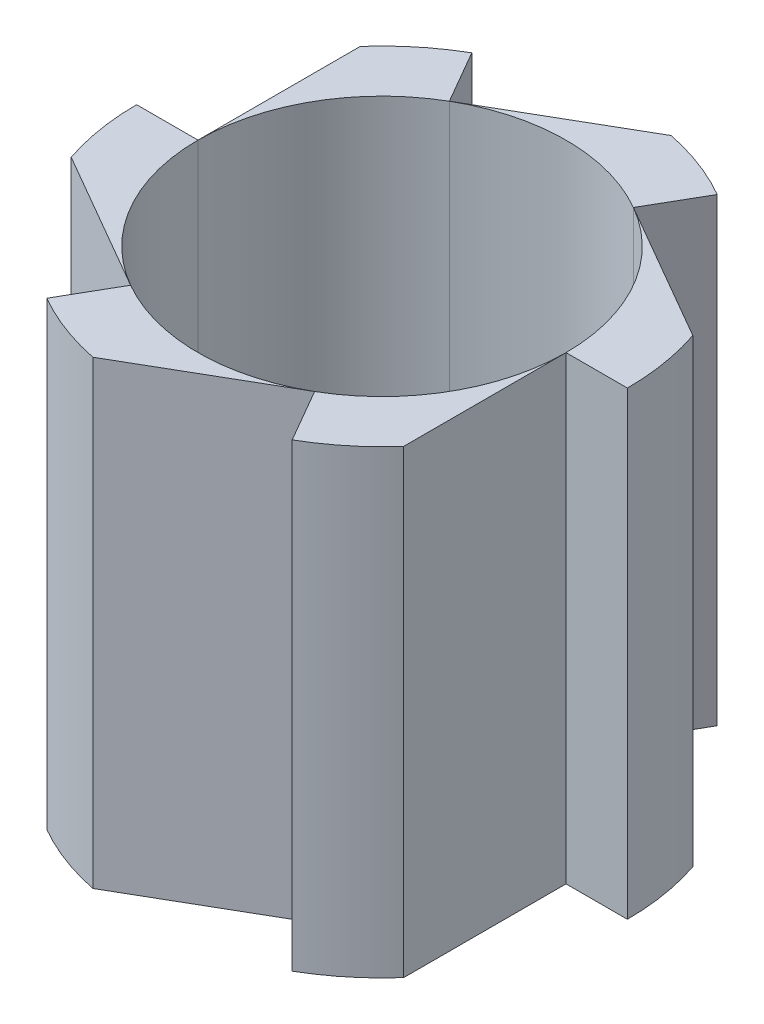
from build123d import *

# Parameters (mm, degrees)
BOSS_EXTRUDE1_DEPTH   = 45
BOSS_EXTRUDE1_2_DEPTH = 45
BOSS_EXTRUDE1_3_DEPTH = 45
BOSS_EXTRUDE1_4_DEPTH = 45
BOSS_EXTRUDE1_5_DEPTH = 45
BOSS_EXTRUDE1_6_DEPTH = 45


with BuildPart() as part:
    # Sketch1 → Boss-Extrude1 (new body)
    with BuildSketch(Plane(origin=(0, 0, 0), x_dir=(1, 0, 0), z_dir=(0, 1, 0))):
        with BuildLine():
            Line((-4.747727085, -23.525711201), (9, -15.588457268))
            ThreePointArc((9, -15.588457268), (0, -18), (-9, -15.588457268))
            Line((-9, -15.588457268), (-12, -20.784609691))
            ThreePointArc((-12, -20.784609691), (-8.485281374, -22.449944321), (-4.747727085, -23.525711201))
        make_face()
    extrude(amount=BOSS_EXTRUDE1_DEPTH)


with BuildPart() as body_2:
    # Sketch1 → Boss-Extrude1 2 (new body)
    with BuildSketch(Plane(origin=(0, 0, 0), x_dir=(1, 0, 0), z_dir=(0, 1, 0))):
        with BuildLine():
            Line((18, -15.874507866), (18, 0))
            ThreePointArc((18, 0), (15.588457268, -9), (9, -15.588457268))
            Line((9, -15.588457268), (12, -20.784609691))
            ThreePointArc((12, -20.784609691), (15.199581408, -18.573441389), (18, -15.874507866))
        make_face()
    extrude(amount=BOSS_EXTRUDE1_2_DEPTH)


with BuildPart() as body_3:
    # Sketch1 → Boss-Extrude1 3 (new body)
    with BuildSketch(Plane(origin=(0, 0, 0), x_dir=(1, 0, 0), z_dir=(0, 1, 0))):
        with BuildLine():
            ThreePointArc((9, 15.588457268), (15.588457268, 9), (18, 0))
            Line((18, 0), (24, 0))
            ThreePointArc((24, 0), (23.684862782, 3.876502932), (22.747727085, 7.651203335))
            Line((22.747727085, 7.651203335), (9, 15.588457268))
        make_face()
    extrude(amount=BOSS_EXTRUDE1_3_DEPTH)


with BuildPart() as body_4:
    # Sketch1 → Boss-Extrude1 4 (new body)
    with BuildSketch(Plane(origin=(0, 0, 0), x_dir=(1, 0, 0), z_dir=(0, 1, 0))):
        with BuildLine():
            ThreePointArc((-9, 15.588457268), (0, 18), (9, 15.588457268))
            Line((9, 15.588457268), (12, 20.784609691))
            ThreePointArc((12, 20.784609691), (8.485281374, 22.449944321), (4.747727085, 23.525711201))
            Line((4.747727085, 23.525711201), (-9, 15.588457268))
        make_face()
    extrude(amount=BOSS_EXTRUDE1_4_DEPTH)


with BuildPart() as body_5:
    # Sketch1 → Boss-Extrude1 5 (new body)
    with BuildSketch(Plane(origin=(0, 0, 0), x_dir=(1, 0, 0), z_dir=(0, 1, 0))):
        with BuildLine():
            ThreePointArc((-18, 0), (-15.588457268, 9), (-9, 15.588457268))
            Line((-9, 15.588457268), (-12, 20.784609691))
            ThreePointArc((-12, 20.784609691), (-15.199581408, 18.573441389), (-18, 15.874507866))
            Line((-18, 15.874507866), (-18, 0))
        make_face()
    extrude(amount=BOSS_EXTRUDE1_5_DEPTH)


with BuildPart() as body_6:
    # Sketch1 → Boss-Extrude1 6 (new body)
    with BuildSketch(Plane(origin=(0, 0, 0), x_dir=(1, 0, 0), z_dir=(0, 1, 0))):
        with BuildLine():
            Line((-22.747727085, -7.651203335), (-9, -15.588457268))
            ThreePointArc((-9, -15.588457268), (-15.588457268, -9), (-18, 0))
            Line((-18, 0), (-24, 0))
            ThreePointArc((-24, 0), (-23.684862782, -3.876502932), (-22.747727085, -7.651203335))
        make_face()
    extrude(amount=BOSS_EXTRUDE1_6_DEPTH)


solid = Compound([part.part, body_2.part, body_3.part, body_4.part, body_5.part, body_6.part])
